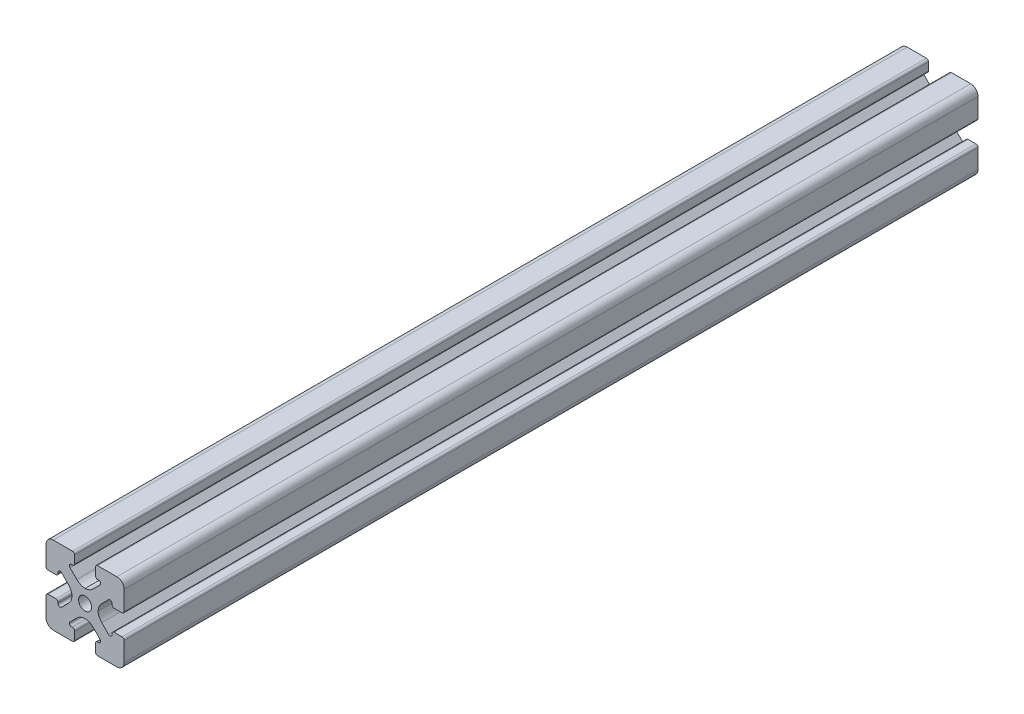
from build123d import *

# Parameters (mm, degrees)
BOSS_EXTRUDE1_DEPTH = 82


with BuildPart() as part:
    # Sketch4 → Boss-Extrude1 (new body, symmetric)
    with BuildSketch(Plane.XY):
        with BuildLine():
            Line((2.4, -7.5), (6.1, -7.5))
            ThreePointArc((6.1, -7.5), (7.089949494, -7.089949494), (7.5, -6.1))
            Line((7.5, -6.1), (7.5, -2.4))
            ThreePointArc((7.5, -2.4), (7.382842712, -2.117157288), (7.1, -2))
            Line((7.1, -2), (5.595331881, -2))
            ThreePointArc((5.595331881, -2), (5.312489168, -2.117157288), (5.195331881, -2.4))
            Line((5.195331881, -2.4), (5.195331881, -2.6))
            ThreePointArc((5.195331881, -2.6), (4.948405254, -2.969551813), (4.512489168, -2.882842712))
            Line((4.512489168, -2.882842712), (3.202943725, -1.57329727))
            ThreePointArc((3.202943725, -1.57329727), (2.682689122, -0.794681232), (2.5, 0.123759005))
            Line((2.5, 0.123759005), (2.5, 0))
            Line((2.5, 0), (1.25, 0))
            ThreePointArc((1.25, 0), (0.883883476, -0.883883476), (0, -1.25))
            Line((0, -1.25), (0, -2.5))
            Line((0, -2.5), (-0.123759005, -2.5))
            ThreePointArc((-0.123759005, -2.5), (0.794681232, -2.682689122), (1.57329727, -3.202943725))
            Line((1.57329727, -3.202943725), (2.882842712, -4.512489168))
            ThreePointArc((2.882842712, -4.512489168), (2.969551813, -4.948405254), (2.6, -5.195331881))
            Line((2.6, -5.195331881), (2.4, -5.195331881))
            ThreePointArc((2.4, -5.195331881), (2.117157288, -5.312489168), (2, -5.595331881))
            Line((2, -5.595331881), (2, -7.1))
            ThreePointArc((2, -7.1), (2.117157288, -7.382842712), (2.4, -7.5))
        make_face()
    extrude(amount=BOSS_EXTRUDE1_DEPTH, both=True)

    # Mirror1: part across plane


with BuildPart() as part_1:
    add(part.part)
    add(part.part.mirror(Plane(origin=(0, 0, 0), x_dir=(0, 0, 1), z_dir=(1, 0, 0))))

    # Mirror2: part across plane


with BuildPart() as part_2:
    add(part_1.part)
    add(part_1.part.mirror(Plane.ZX))


solid = part_2.part
